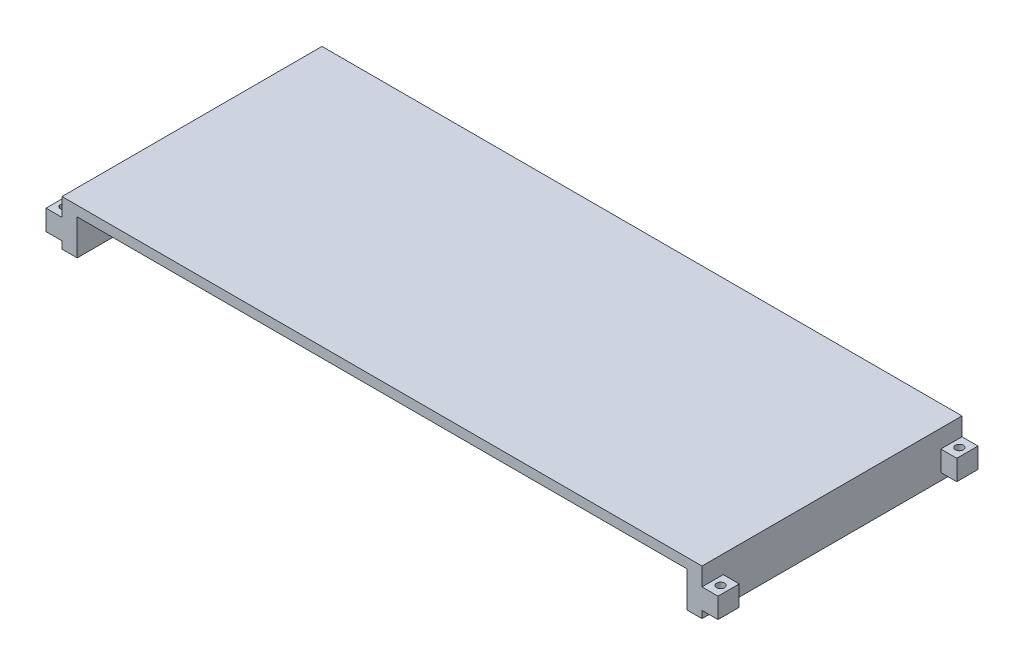
from build123d import *

# Parameters (mm, degrees)
SKETCH1_W           = 1600
SKETCH1_H           = 650
BOSS_EXTRUDE1_DEPTH = 25
BOSS_EXTRUDE2_DEPTH = 89
SKETCH3_W           = 53
SKETCH3_H           = 50.8
BOSS_EXTRUDE3_DEPTH = 40
SKETCH4_R           = 10
CUT_EXTRUDE1_DEPTH  = 129


with BuildPart() as part:
    # Sketch1 → Boss-Extrude1 (new body)
    with BuildSketch(Plane(origin=(0, 0, 0), x_dir=(1, 0, 0), z_dir=(0, 1, 0))):
        with Locations((800, -325)):
            Rectangle(SKETCH1_W, SKETCH1_H)
    extrude(amount=BOSS_EXTRUDE1_DEPTH)

    # Sketch2 → Boss-Extrude2 (add)
    with BuildSketch(Plane.XZ):
        Polygon((38, 306), (38, 0), (0, 0), (0, 650), (38, 650), (38, 344), (1562, 344), (1562, 650), (1600, 650), (1600, 0), (1562, 0), (1562, 306), align=None)
    extrude(amount=BOSS_EXTRUDE2_DEPTH)

    # Sketch3 → Boss-Extrude3 (add)
    with BuildSketch(Plane.ZY):
        with Locations((26.5, -45.6)):
            Rectangle(SKETCH3_W, SKETCH3_H)
        with Locations((623.5, -45.6)):
            Rectangle(SKETCH3_W, SKETCH3_H)
    boss_extrude3 = extrude(amount=BOSS_EXTRUDE3_DEPTH)

    # Sketch4 → Cut-Extrude1 (cut)
    with BuildSketch(Plane.XZ.offset(71)):
        with Locations((-20, 26.5)):
            Circle(SKETCH4_R)
        with Locations((-20, 623.5)):
            Circle(SKETCH4_R)
    cut_extrude1 = extrude(amount=-CUT_EXTRUDE1_DEPTH, mode=Mode.SUBTRACT)

    # Mirror1: Boss-Extrude3, Cut-Extrude1 across plane
    add(boss_extrude3.mirror(Plane(origin=(800, 0, 0), x_dir=(0, 0, 1), z_dir=(1, 0, 0))))
    add(cut_extrude1.mirror(Plane(origin=(800, 0, 0), x_dir=(0, 0, 1), z_dir=(1, 0, 0))), mode=Mode.SUBTRACT)


solid = part.part
